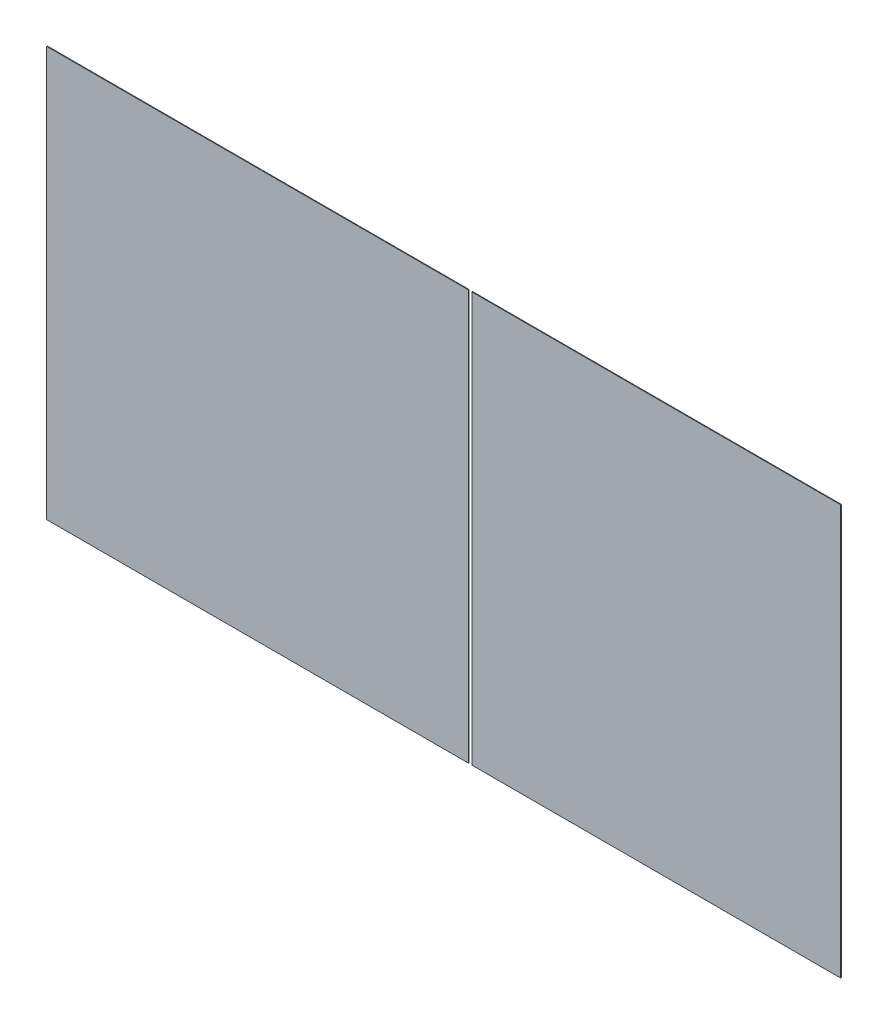
from build123d import *

# Parameters (mm, degrees)
SKETCH_1_W          = 1778
SKETCH_1_H          = 918
EXTRUDE_1_DEPTH     = 1.5
SKETCH_2_W          = 7.768523467
SKETCH_2_H          = 1643.967023226
CUT_EXTRUDE_1_DEPTH = 2.5


with BuildPart() as part:
    # 草图1 → 凸台-拉伸1 (new body)
    with BuildSketch(Plane.XY):
        with Locations((-325.240719956, 167.925186119)):
            Rectangle(SKETCH_1_W, SKETCH_1_H)
    extrude(amount=EXTRUDE_1_DEPTH)

    # 草图2 → 切除-拉伸1 (cut, through all)
    with BuildSketch(Plane.XY.offset(1.5)):
        with Locations((-266.183880817, 60.76189507)):
            Rectangle(SKETCH_2_W, SKETCH_2_H)
    extrude(amount=-CUT_EXTRUDE_1_DEPTH, mode=Mode.SUBTRACT)


solid = part.part
